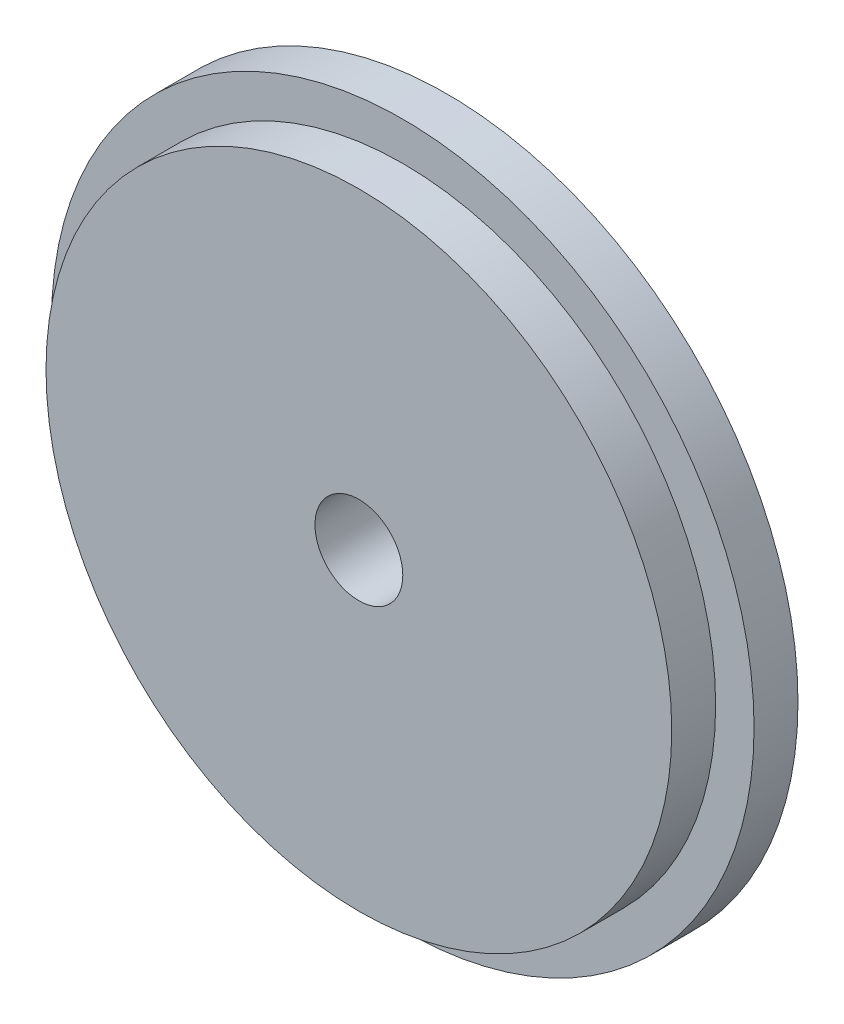
from build123d import *

# Parameters (mm, degrees)
ESQUISSE1_R             = 16
BOSS_EXTRU_1_DEPTH      = 2
ESQUISSE2_R             = 14.25
BOSS_EXTRU_2_DEPTH      = 2
ESQUISSE3_R             = 2
ENL_V_MAT_EXTRU_1_DEPTH = 5


with BuildPart() as part:
    # Esquisse1 → Boss.-Extru.1 (new body)
    with BuildSketch(Plane.XY):
        Circle(ESQUISSE1_R)
    extrude(amount=BOSS_EXTRU_1_DEPTH)

    # Esquisse2 → Boss.-Extru.2 (add)
    with BuildSketch(Plane.XY.offset(2)):
        Circle(ESQUISSE2_R)
    extrude(amount=BOSS_EXTRU_2_DEPTH)

    # Esquisse3 → Enlèv. mat.-Extru.1 (cut, through all)
    with BuildSketch(Plane.XY.offset(4)):
        Circle(ESQUISSE3_R)
    extrude(amount=-ENL_V_MAT_EXTRU_1_DEPTH, mode=Mode.SUBTRACT)


solid = part.part
